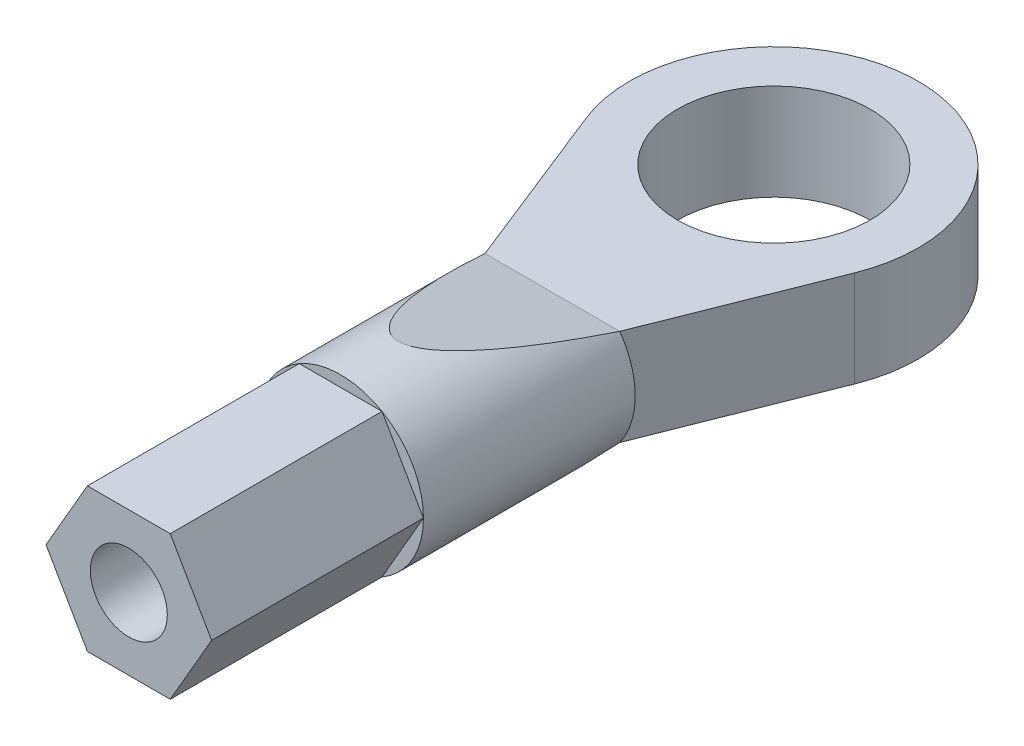
from build123d import *

# Parameters (mm, degrees)
SKETCH1_R               = 2.5
BOSS_EXTRUDE1_DEPTH     = 2.5
SKETCH2_R               = 2.150581317
BOSS_EXTRUDE2_DEPTH     = 5.5
CUT_EXTRUDE1_DEPTH      = 5.5
CUT_EXTRUDE1_DEPTH_BACK = 5.5
SKETCH5_R               = 1
BOSS_EXTRUDE4_DEPTH     = 5.5


with BuildPart() as part:
    # Sketch1 → Boss-Extrude1 (new body)
    with BuildSketch(Plane(origin=(0, 0, 0), x_dir=(1, 0, 0), z_dir=(0, 1, 0))):
        with BuildLine():
            Line((1.75, -5.75), (3.484844943, -1.385047191))
            ThreePointArc((3.484844943, -1.385047191), (0, 3.75), (-3.484844943, -1.385047191))
            Line((-3.484844943, -1.385047191), (-1.75, -5.75))
            Line((-1.75, -5.75), (1.75, -5.75))
        make_face()
        Circle(SKETCH1_R, mode=Mode.SUBTRACT)
    extrude(amount=BOSS_EXTRUDE1_DEPTH)

    # Sketch2 → Boss-Extrude2 (add)
    with BuildSketch(Plane.XY.offset(5.75)):
        with Locations((0, 1.25)):
            Circle(SKETCH2_R)
    extrude(amount=BOSS_EXTRUDE2_DEPTH)

    # Sketch4 → Cut-Extrude1 (cut, two sides: drawn at the far end of the back side and taken through both)
    with BuildSketch(Plane(origin=(0, 0, 0), x_dir=(0, 0, -1), z_dir=(1, 0, 0)).offset(-CUT_EXTRUDE1_DEPTH_BACK)):
        Polygon((-5.75, 3.400581317), (-9.75, 3.400581317), (-5.75, 2.5), align=None)
        Polygon((-5.75, -0.900581317), (-5.75, 0), (-9.75, -0.900581317), align=None)
    extrude(amount=CUT_EXTRUDE1_DEPTH + CUT_EXTRUDE1_DEPTH_BACK, mode=Mode.SUBTRACT)

    # Sketch5 → Boss-Extrude4 (add)
    with BuildSketch(Plane.XY.offset(11.25)):
        Polygon((2.150581317, 1.25), (1.075290658, 3.112458053), (-1.075290658, 3.112458053), (-2.150581317, 1.25), (-1.075290658, -0.612458053), (1.075290658, -0.612458053), align=None)
        with Locations((0, 1.25)):
            Circle(SKETCH5_R, mode=Mode.SUBTRACT)
    extrude(amount=BOSS_EXTRUDE4_DEPTH)


solid = part.part
